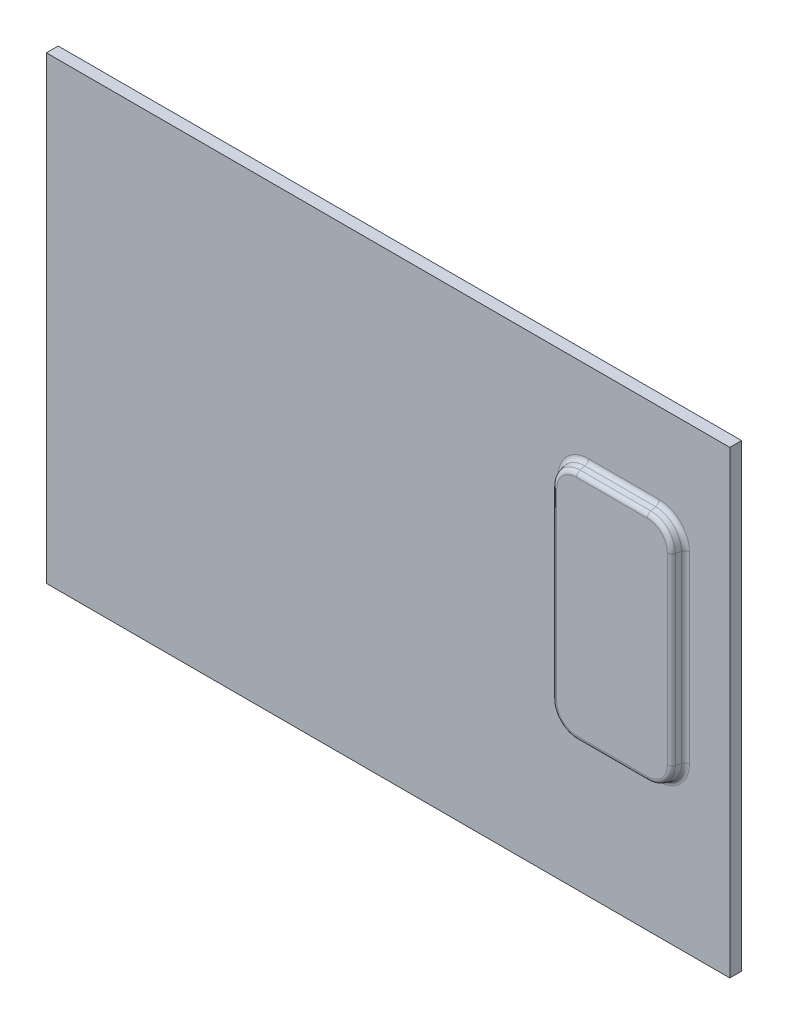
from build123d import *

# Parameters (mm, degrees)
SKETCH_1_W      = 290
SKETCH_1_H      = 195
EXTRUDE_1_DEPTH = 5
SKETCH_2_W      = 50
SKETCH_2_H      = 98
EXTRUDE_2_DEPTH = 5
FILLET_1_R      = 10
DRAFT_1_ANGLE   = 15
FILLET_2_R      = 2


with BuildPart() as part:
    # 草图1 → 凸台-拉伸1 (new body)
    with BuildSketch(Plane.XY):
        Rectangle(SKETCH_1_W, SKETCH_1_H)
    extrude(amount=EXTRUDE_1_DEPTH)

    # 草图2 → 凸台-拉伸2 (add)
    with BuildSketch(Plane.XY.offset(5)):
        with Locations((100, 11.5)):
            Rectangle(SKETCH_2_W, SKETCH_2_H)
    extrude(amount=EXTRUDE_2_DEPTH)

    # 圆角1
    fillet_1_edges = [part.edges().sort_by_distance(p)[0] for p in [
        (125, -37.5, 7.5),
        (125, 60.5, 7.5),
        (75, 60.5, 7.5),
        (75, -37.5, 7.5),
    ]]
    fillet(fillet_1_edges, radius=FILLET_1_R)

    # 拔模1
    draft_1_faces = [part.faces().sort_by_distance(p)[0] for p in [
        (75, 11.5, 7.5),
        (77.928932188, 57.571067812, 7.5),
        (100, 60.5, 7.5),
        (122.071067812, 57.571067812, 7.5),
        (125, 11.5, 7.5),
        (122.071067812, -34.571067812, 7.5),
        (100, -37.5, 7.5),
        (77.928932188, -34.571067812, 7.5),
    ]]
    draft(draft_1_faces, Plane.XY.offset(10), DRAFT_1_ANGLE)

    # 圆角2
    fillet_2_edges = [part.edges().sort_by_distance(p)[0] for p in [
        (100, 61.839745962, 5),
        (100, 60.5, 10),
        (126.339745962, 11.5, 5),
        (125, 11.5, 10),
        (75, 11.5, 10),
        (100, -37.5, 10),
        (77.928932188, -34.571067812, 10),
        (122.071067812, -34.571067812, 10),
        (77.928932188, 57.571067812, 10),
        (122.071067812, 57.571067812, 10),
        (73.660254038, 11.5, 5),
        (100, -38.839745962, 5),
        (123.018411267, 58.518411267, 5),
        (76.981588733, 58.518411267, 5),
        (123.018411267, -35.518411267, 5),
        (76.981588733, -35.518411267, 5),
    ]]
    fillet(fillet_2_edges, radius=FILLET_2_R)


solid = part.part
